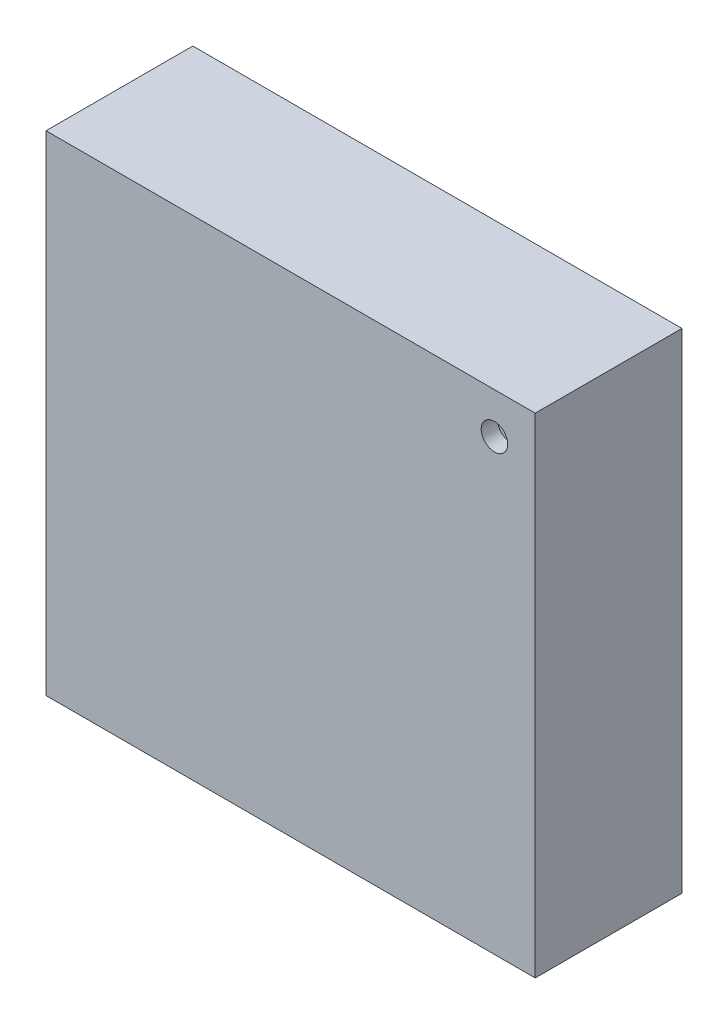
from build123d import *

# Parameters (mm, degrees)
SKETCH2_W           = 3
SKETCH2_H           = 3
BOSS_EXTRUDE1_DEPTH = 0.9
SKETCH3_R           = 0.081261336
CUT_EXTRUDE1_DEPTH  = 0.1
SKETCH4_W           = 0.25
SKETCH4_H           = 0.325
BOSS_EXTRUDE2_DEPTH = 0.05
CIRPATTERN1_COUNT   = 2
CIRPATTERN1_ANGLE   = 90


with BuildPart() as part:
    # Sketch2 → Boss-Extrude1 (new body)
    with BuildSketch(Plane.XY):
        with Locations((1.5, 1.5)):
            Rectangle(SKETCH2_W, SKETCH2_H)
    extrude(amount=BOSS_EXTRUDE1_DEPTH)

    # Sketch3 → Cut-Extrude1 (cut)
    with BuildSketch(Plane.XY.offset(0.9)):
        with Locations((2.75, 2.75)):
            Circle(SKETCH3_R)
    extrude(amount=-CUT_EXTRUDE1_DEPTH, mode=Mode.SUBTRACT)

    # Sketch4 → Boss-Extrude2 (add)
    with BuildSketch(Plane(origin=(0, 0, 0), x_dir=(-1, 0, 0), z_dir=(0, 0, -1))):
        with Locations((-2.25, 2.7875)):
            Rectangle(SKETCH4_W, SKETCH4_H)
        with Locations((-1.75, 2.7875)):
            Rectangle(SKETCH4_W, SKETCH4_H)
        with Locations((-1.25, 2.7875)):
            Rectangle(SKETCH4_W, SKETCH4_H)
        with Locations((-0.75, 2.7875)):
            Rectangle(SKETCH4_W, SKETCH4_H)
        with Locations((-0.75, 0.2125)):
            Rectangle(SKETCH4_W, SKETCH4_H)
        with Locations((-1.25, 0.2125)):
            Rectangle(SKETCH4_W, SKETCH4_H)
        with Locations((-1.75, 0.2125)):
            Rectangle(SKETCH4_W, SKETCH4_H)
        with Locations((-2.25, 0.2125)):
            Rectangle(SKETCH4_W, SKETCH4_H)
    boss_extrude2 = extrude(amount=BOSS_EXTRUDE2_DEPTH)

    # CirPattern1: Boss-Extrude2 ×2 about axis
    cirpattern1_axis = Axis((1.5, 1.5, 0.945), (0, 0, -1))
    for i in range(1, CIRPATTERN1_COUNT):
        add(boss_extrude2.rotate(cirpattern1_axis, i * CIRPATTERN1_ANGLE / (CIRPATTERN1_COUNT - 1)))


solid = part.part
